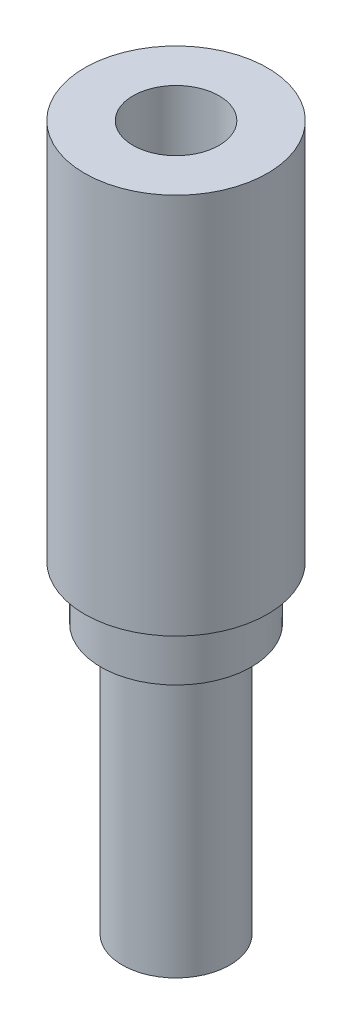
from build123d import *

# Parameters (mm, degrees)
SKETCH1_R           = 8.5
BOSS_EXTRUDE1_DEPTH = 35.5
SKETCH3_R           = 7
BOSS_EXTRUDE2_DEPTH = 5
SKETCH5_R           = 5
BOSS_EXTRUDE3_DEPTH = 25
SKETCH2_R           = 4
CUT_EXTRUDE1_DEPTH  = 17


with BuildPart() as part:
    # Sketch1 → Boss-Extrude1 (new body)
    with BuildSketch(Plane(origin=(0, 0, 0), x_dir=(1, 0, 0), z_dir=(0, 1, 0))):
        Circle(SKETCH1_R)
    extrude(amount=BOSS_EXTRUDE1_DEPTH)

    # Sketch3 → Boss-Extrude2 (add)
    with BuildSketch(Plane(origin=(0, 0, 0), x_dir=(-1, 0, 0), z_dir=(0, -1, 0))):
        Circle(SKETCH3_R)
    extrude(amount=BOSS_EXTRUDE2_DEPTH)

    # Sketch5 → Boss-Extrude3 (add)
    with BuildSketch(Plane(origin=(0, -5, 0), x_dir=(-1, 0, 0), z_dir=(0, -1, 0))):
        Circle(SKETCH5_R)
    extrude(amount=BOSS_EXTRUDE3_DEPTH)

    # Sketch2 → Cut-Extrude1 (cut)
    with BuildSketch(Plane(origin=(0, 35.5, 0), x_dir=(1, 0, 0), z_dir=(0, 1, 0))):
        Circle(SKETCH2_R)
    extrude(amount=-CUT_EXTRUDE1_DEPTH, mode=Mode.SUBTRACT)


solid = part.part
